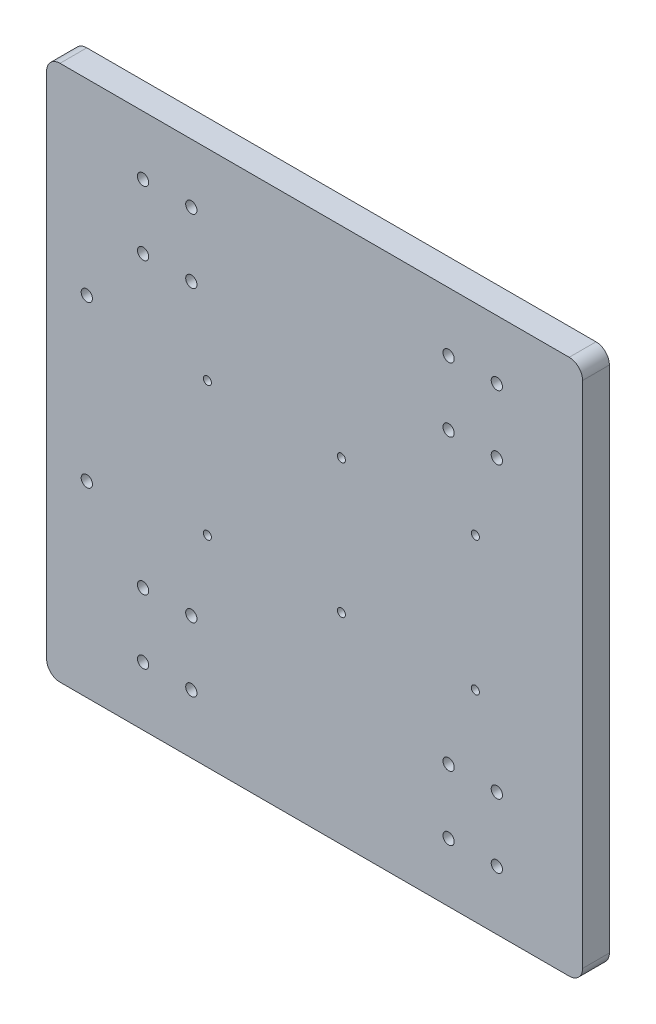
from build123d import *

# Parameters (mm, degrees)
SKETCH2_R           = 2.1
SKETCH2_R_2         = 1.5
BOSS_EXTRUDE1_DEPTH = 10


with BuildPart() as part:
    # Sketch2 → Boss-Extrude1 (new body)
    with BuildSketch(Plane.XY):
        with BuildLine():
            Line((-11, 0), (179, 0))
            ThreePointArc((179, 0), (182.535533906, 1.464466094), (184, 5))
            Line((184, 5), (184, 195))
            ThreePointArc((184, 195), (182.535533906, 198.535533906), (179, 200))
            Line((179, 200), (-11, 200))
            ThreePointArc((-11, 200), (-14.535533906, 198.535533906), (-16, 195))
            Line((-16, 195), (-16, 5))
            ThreePointArc((-16, 5), (-14.535533906, 1.464466094), (-11, 0))
        make_face()
        with Locations((-1, 70)):
            Circle(SKETCH2_R, mode=Mode.SUBTRACT)
        with Locations((152, 178)):
            Circle(SKETCH2_R, mode=Mode.SUBTRACT)
        with Locations((152, 154)):
            Circle(SKETCH2_R, mode=Mode.SUBTRACT)
        with Locations((152, 22)):
            Circle(SKETCH2_R, mode=Mode.SUBTRACT)
        with Locations((152, 46)):
            Circle(SKETCH2_R, mode=Mode.SUBTRACT)
        with Locations((20, 178)):
            Circle(SKETCH2_R, mode=Mode.SUBTRACT)
        with Locations((38, 154)):
            Circle(SKETCH2_R, mode=Mode.SUBTRACT)
        with Locations((20, 22)):
            Circle(SKETCH2_R, mode=Mode.SUBTRACT)
        with Locations((38, 46)):
            Circle(SKETCH2_R, mode=Mode.SUBTRACT)
        with Locations((20, 46)):
            Circle(SKETCH2_R, mode=Mode.SUBTRACT)
        with Locations((38, 22)):
            Circle(SKETCH2_R, mode=Mode.SUBTRACT)
        with Locations((38, 178)):
            Circle(SKETCH2_R, mode=Mode.SUBTRACT)
        with Locations((20, 154)):
            Circle(SKETCH2_R, mode=Mode.SUBTRACT)
        with Locations((134, 46)):
            Circle(SKETCH2_R, mode=Mode.SUBTRACT)
        with Locations((134, 22)):
            Circle(SKETCH2_R, mode=Mode.SUBTRACT)
        with Locations((134, 154)):
            Circle(SKETCH2_R, mode=Mode.SUBTRACT)
        with Locations((134, 178)):
            Circle(SKETCH2_R, mode=Mode.SUBTRACT)
        with Locations((-1, 130)):
            Circle(SKETCH2_R, mode=Mode.SUBTRACT)
        with Locations((144, 125)):
            Circle(SKETCH2_R_2, mode=Mode.SUBTRACT)
        with Locations((144, 75)):
            Circle(SKETCH2_R_2, mode=Mode.SUBTRACT)
        with Locations((94, 125)):
            Circle(SKETCH2_R_2, mode=Mode.SUBTRACT)
        with Locations((94, 75)):
            Circle(SKETCH2_R_2, mode=Mode.SUBTRACT)
        with Locations((44, 125)):
            Circle(SKETCH2_R_2, mode=Mode.SUBTRACT)
        with Locations((44, 75)):
            Circle(SKETCH2_R_2, mode=Mode.SUBTRACT)
    extrude(amount=BOSS_EXTRUDE1_DEPTH)


solid = part.part
